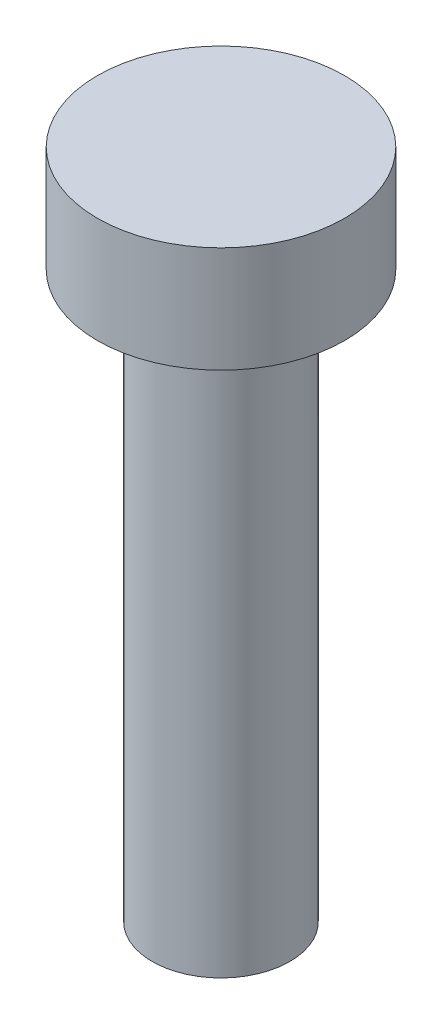
from build123d import *

# Parameters (mm, degrees)
SKETCH1_R           = 3.5
BOSS_EXTRUDE1_DEPTH = 3
SKETCH2_R           = 1.95
BOSS_EXTRUDE2_DEPTH = 16


with BuildPart() as part:
    # Sketch1 → Boss-Extrude1 (new body)
    with BuildSketch(Plane(origin=(0, 0, 0), x_dir=(1, 0, 0), z_dir=(0, 1, 0))):
        Circle(SKETCH1_R)
    extrude(amount=BOSS_EXTRUDE1_DEPTH)

    # Sketch2 → Boss-Extrude2 (add)
    with BuildSketch(Plane.XZ):
        Circle(SKETCH2_R)
    extrude(amount=BOSS_EXTRUDE2_DEPTH)


solid = part.part
